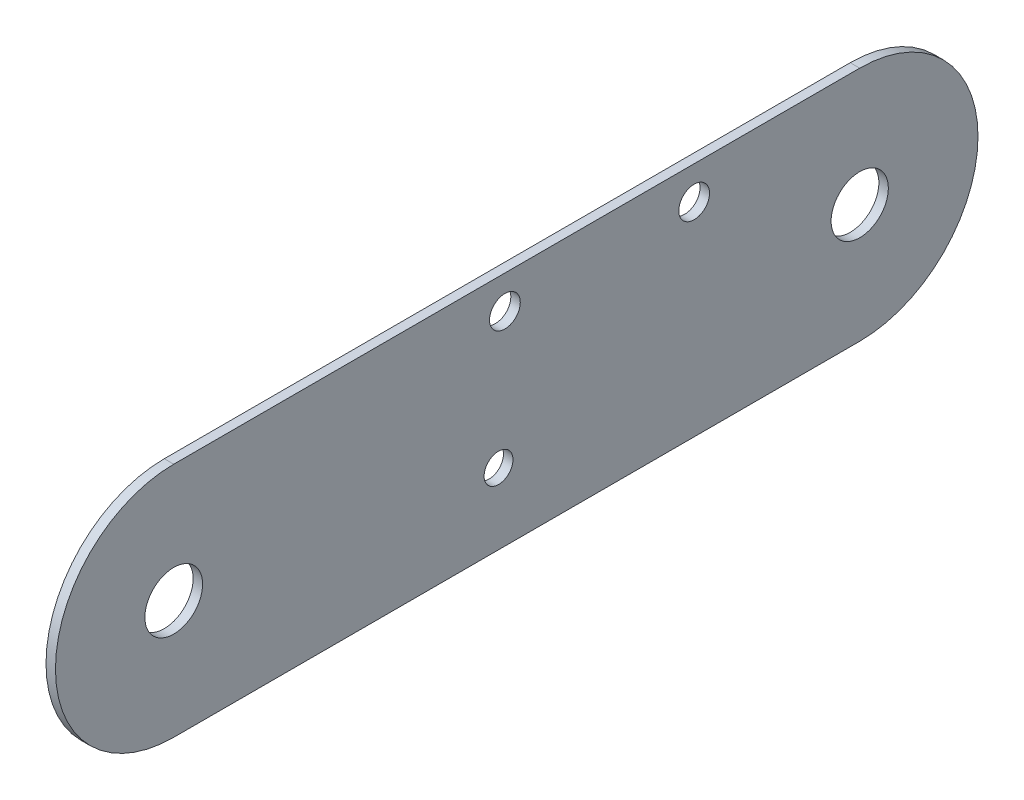
from build123d import *

# Parameters (mm, degrees)
SKETCH_1_R      = 6.05
SKETCH_1_R_2    = 6.1
SKETCH_1_R_3    = 3.05
SKETCH_1_R_4    = 3.25
EXTRUDE_1_DEPTH = 2


with BuildPart() as part:
    # 草图1 → 凸台-拉伸1 (new body)
    with BuildSketch(Plane(origin=(0, 0, 0), x_dir=(0, 0, -1), z_dir=(1, 0, 0))):
        with BuildLine():
            Line((19.426316451, -58.647367097), (-125.573683549, -58.647367097))
            ThreePointArc((-125.573683549, -58.647367097), (-150.573683549, -33.647367097), (-125.573683549, -8.647367097))
            Line((-125.573683549, -8.647367097), (4.992559722, -8.647367097))
            Line((4.992559722, -8.647367097), (19.426316451, -8.647367097))
            ThreePointArc((19.426316451, -8.647367097), (44.426316451, -33.647367097), (19.426316451, -58.647367097))
        make_face()
        with Locations((19.426316451, -33.647367097)):
            Circle(SKETCH_1_R, mode=Mode.SUBTRACT)
        with Locations((-125.573683549, -33.647367097)):
            Circle(SKETCH_1_R_2, mode=Mode.SUBTRACT)
        with Locations((-56.921571535, -43.647367097)):
            Circle(SKETCH_1_R_3, mode=Mode.SUBTRACT)
        with Locations((-15.573683549, -15.647367097)):
            Circle(SKETCH_1_R_4, mode=Mode.SUBTRACT)
        with Locations((-55.573683549, -15.647367097)):
            Circle(SKETCH_1_R_4, mode=Mode.SUBTRACT)
    extrude(amount=EXTRUDE_1_DEPTH)


solid = part.part
